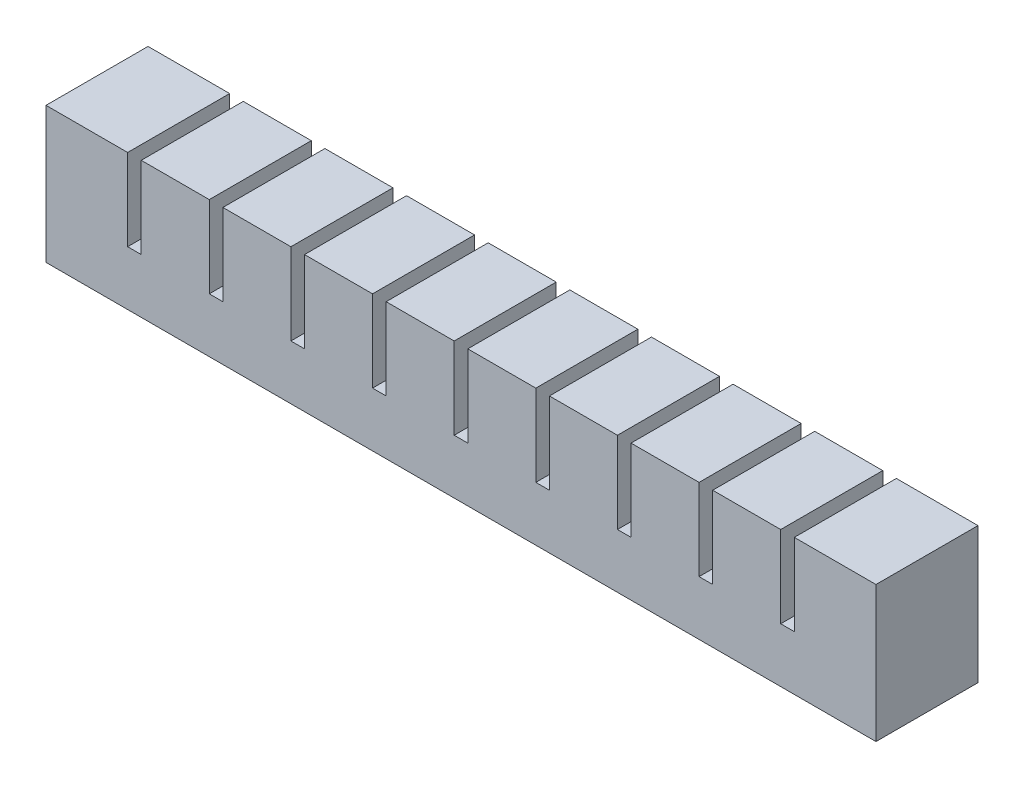
from build123d import *

# Parameters (mm, degrees)
SKETCH1_W           = 10
SKETCH1_H           = 15
BOSS_EXTRUDE1_DEPTH = 15
SKETCH2_W           = 4
SKETCH2_H           = 9
CUT_EXTRUDE1_DEPTH  = 12
SKETCH3_W           = 15
SKETCH3_H           = 3
BOSS_EXTRUDE2_DEPTH = 2
LPATTERN1_COUNT     = 10
LPATTERN1_PITCH     = 12
SKETCH4_W           = 15
SKETCH4_H           = 12
BOSS_EXTRUDE3_DEPTH = 2
SKETCH5_W           = 15
SKETCH5_H           = 15
BOSS_EXTRUDE4_DEPTH = 2
SKETCH6_W           = 104
SKETCH6_H           = 3
CUT_EXTRUDE2_DEPTH  = 2.5
SKETCH7_W           = 122
SKETCH7_H           = 15
BOSS_EXTRUDE5_DEPTH = 3
SKETCH8_W           = 122
SKETCH8_H           = 15
BOSS_EXTRUDE6_DEPTH = 2


with BuildPart() as part:
    # Sketch1 → Boss-Extrude1 (new body)
    with BuildSketch(Plane.XY):
        with Locations((5, 7.5)):
            Rectangle(SKETCH1_W, SKETCH1_H)
    extrude(amount=BOSS_EXTRUDE1_DEPTH)

    # Sketch2 → Cut-Extrude1 (cut)
    with BuildSketch(Plane.XZ):
        with Locations((5, 7.5)):
            Rectangle(SKETCH2_W, SKETCH2_H)
    extrude(amount=-CUT_EXTRUDE1_DEPTH, mode=Mode.SUBTRACT)

    # Sketch3 → Boss-Extrude2 (add)
    with BuildSketch(Plane(origin=(10, 0, 0), x_dir=(0, 0, -1), z_dir=(1, 0, 0))):
        with Locations((-7.5, 1.5)):
            Rectangle(SKETCH3_W, SKETCH3_H)
    extrude(amount=BOSS_EXTRUDE2_DEPTH)


with BuildPart() as lpattern1_1:
    # LPattern1: pattern copy
    add(part.part.moved(Location(Vector(1, 0, 0) * (1 * LPATTERN1_PITCH))))


with BuildPart() as lpattern1_2:
    # LPattern1: pattern copy
    add(part.part.moved(Location(Vector(1, 0, 0) * (2 * LPATTERN1_PITCH))))


with BuildPart() as lpattern1_3:
    # LPattern1: pattern copy
    add(part.part.moved(Location(Vector(1, 0, 0) * (3 * LPATTERN1_PITCH))))


with BuildPart() as lpattern1_4:
    # LPattern1: pattern copy
    add(part.part.moved(Location(Vector(1, 0, 0) * (4 * LPATTERN1_PITCH))))


with BuildPart() as lpattern1_5:
    # LPattern1: pattern copy
    add(part.part.moved(Location(Vector(1, 0, 0) * (5 * LPATTERN1_PITCH))))


with BuildPart() as lpattern1_6:
    # LPattern1: pattern copy
    add(part.part.moved(Location(Vector(1, 0, 0) * (6 * LPATTERN1_PITCH))))


with BuildPart() as lpattern1_7:
    # LPattern1: pattern copy
    add(part.part.moved(Location(Vector(1, 0, 0) * (7 * LPATTERN1_PITCH))))


with BuildPart() as lpattern1_8:
    # LPattern1: pattern copy
    add(part.part.moved(Location(Vector(1, 0, 0) * (8 * LPATTERN1_PITCH))))


with BuildPart() as lpattern1_9:
    # LPattern1: pattern copy
    add(part.part.moved(Location(Vector(1, 0, 0) * (9 * LPATTERN1_PITCH))))

    # Combine1: union LPattern1_1, LPattern1_2, LPattern1_3, LPattern1_4, LPattern1_5, part, LPattern1_6, LPattern1_7, LPattern1_8
    add(lpattern1_1.part)
    add(lpattern1_2.part)
    add(lpattern1_3.part)
    add(lpattern1_4.part)
    add(lpattern1_5.part)
    add(part.part)
    add(lpattern1_6.part)
    add(lpattern1_7.part)
    add(lpattern1_8.part)

    # Sketch4 → Boss-Extrude3 (add)
    with BuildSketch(Plane(origin=(118, 0, 0), x_dir=(0, 0, -1), z_dir=(1, 0, 0))):
        with Locations((-7.5, 9)):
            Rectangle(SKETCH4_W, SKETCH4_H)
    extrude(amount=BOSS_EXTRUDE3_DEPTH)

    # Sketch5 → Boss-Extrude4 (add)
    with BuildSketch(Plane.ZY):
        with Locations((7.5, 7.5)):
            Rectangle(SKETCH5_W, SKETCH5_H)
    extrude(amount=BOSS_EXTRUDE4_DEPTH)

    # Sketch6 → Cut-Extrude2 (cut)
    with BuildSketch(Plane.XZ):
        with Locations((59, 7.5)):
            Rectangle(SKETCH6_W, SKETCH6_H)
    extrude(amount=-CUT_EXTRUDE2_DEPTH, mode=Mode.SUBTRACT)

    # Sketch7 → Boss-Extrude5 (add)
    with BuildSketch(Plane.XZ):
        with Locations((59, 7.5)):
            Rectangle(SKETCH7_W, SKETCH7_H)
    extrude(amount=BOSS_EXTRUDE5_DEPTH)

    # Sketch8 → Boss-Extrude6 (add)
    with BuildSketch(Plane.XZ.offset(3)):
        with Locations((59, 7.5)):
            Rectangle(SKETCH8_W, SKETCH8_H)
    extrude(amount=BOSS_EXTRUDE6_DEPTH)


solid = lpattern1_9.part
